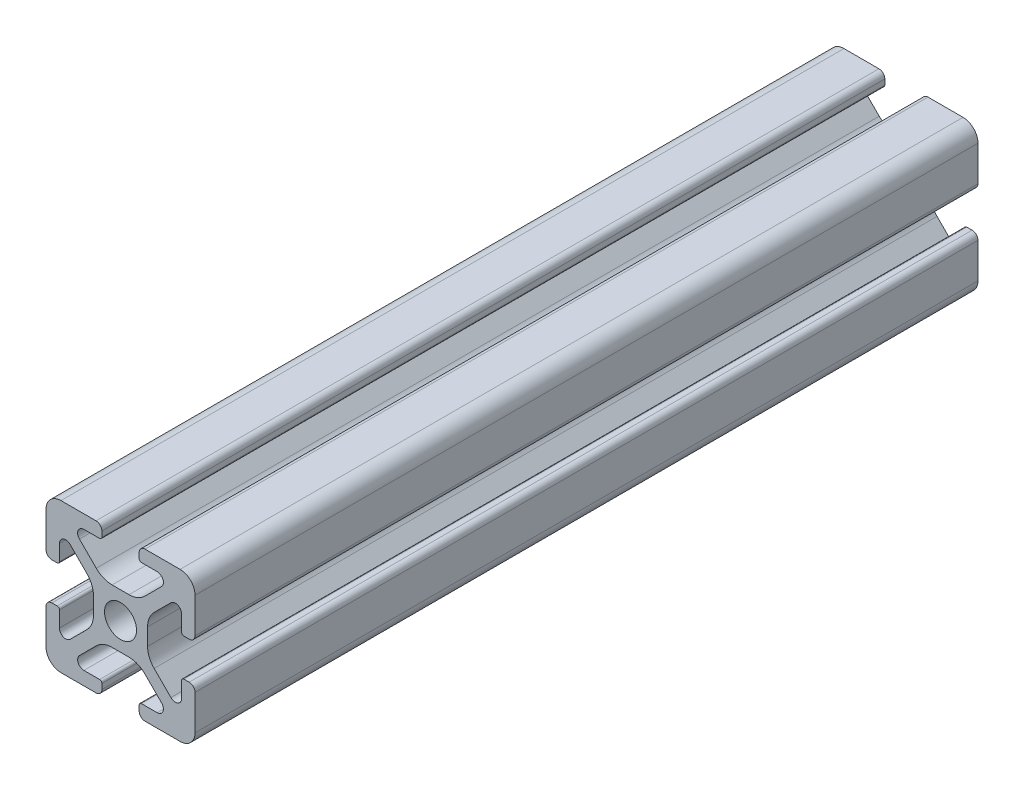
from build123d import *

# Parameters (mm, degrees)
SKETCH1_R           = 2.1463
BOSS_EXTRUDE1_DEPTH = 52.5


with BuildPart() as part:
    # Sketch1 → Boss-Extrude1 (new body, symmetric)
    with BuildSketch(Plane.XY):
        with BuildLine():
            Line((-9.9949, 7.9883), (-9.9949, 3.2893))
            ThreePointArc((-9.9949, 3.2893), (-9.76427588, 2.73252412), (-9.2075, 2.5019))
            Line((-9.2075, 2.5019), (-8.4963, 2.5019))
            ThreePointArc((-8.4963, 2.5019), (-8.280773853, 2.591173853), (-8.1915, 2.8067))
            Line((-8.1915, 2.8067), (-8.1915, 4.9149))
            ThreePointArc((-8.1915, 4.9149), (-7.674065253, 5.689295824), (-6.760603096, 5.507596904))
            Line((-6.760603096, 5.507596904), (-4.505765747, 3.252759555))
            ThreePointArc((-4.505765747, 3.252759555), (-3.856054457, 2.280397894), (-3.627906192, 1.133419111))
            Line((-3.627906192, 1.133419111), (-3.627906192, -1.133419111))
            ThreePointArc((-3.627906192, -1.133419111), (-3.856054457, -2.280397894), (-4.505765747, -3.252759555))
            Line((-4.505765747, -3.252759555), (-6.760603096, -5.507596904))
            ThreePointArc((-6.760603096, -5.507596904), (-7.674065253, -5.689295824), (-8.1915, -4.9149))
            Line((-8.1915, -4.9149), (-8.1915, -2.8067))
            ThreePointArc((-8.1915, -2.8067), (-8.280773853, -2.591173853), (-8.4963, -2.5019))
            Line((-8.4963, -2.5019), (-9.2075, -2.5019))
            ThreePointArc((-9.2075, -2.5019), (-9.76427588, -2.73252412), (-9.9949, -3.2893))
            Line((-9.9949, -3.2893), (-9.9949, -7.9883))
            ThreePointArc((-9.9949, -7.9883), (-9.407180467, -9.407180467), (-7.9883, -9.9949))
            Line((-7.9883, -9.9949), (-3.2893, -9.9949))
            ThreePointArc((-3.2893, -9.9949), (-2.73252412, -9.76427588), (-2.5019, -9.2075))
            Line((-2.5019, -9.2075), (-2.5019, -8.4963))
            ThreePointArc((-2.5019, -8.4963), (-2.591173853, -8.280773853), (-2.8067, -8.1915))
            Line((-2.8067, -8.1915), (-4.9149, -8.1915))
            ThreePointArc((-4.9149, -8.1915), (-5.689295824, -7.674065253), (-5.507596904, -6.760603096))
            Line((-5.507596904, -6.760603096), (-3.252759555, -4.505765747))
            ThreePointArc((-3.252759555, -4.505765747), (-2.280397894, -3.856054457), (-1.133419111, -3.627906192))
            Line((-1.133419111, -3.627906192), (1.133419111, -3.627906192))
            ThreePointArc((1.133419111, -3.627906192), (2.280397894, -3.856054457), (3.252759555, -4.505765747))
            Line((3.252759555, -4.505765747), (5.507596904, -6.760603096))
            ThreePointArc((5.507596904, -6.760603096), (5.689295824, -7.674065253), (4.9149, -8.1915))
            Line((4.9149, -8.1915), (2.8067, -8.1915))
            ThreePointArc((2.8067, -8.1915), (2.591173853, -8.280773853), (2.5019, -8.4963))
            Line((2.5019, -8.4963), (2.5019, -9.2075))
            ThreePointArc((2.5019, -9.2075), (2.73252412, -9.76427588), (3.2893, -9.9949))
            Line((3.2893, -9.9949), (7.9883, -9.9949))
            ThreePointArc((7.9883, -9.9949), (9.407180467, -9.407180467), (9.9949, -7.9883))
            Line((9.9949, -7.9883), (9.9949, -3.2893))
            ThreePointArc((9.9949, -3.2893), (9.76427588, -2.73252412), (9.2075, -2.5019))
            Line((9.2075, -2.5019), (8.4963, -2.5019))
            ThreePointArc((8.4963, -2.5019), (8.280773853, -2.591173853), (8.1915, -2.8067))
            Line((8.1915, -2.8067), (8.1915, -4.9149))
            ThreePointArc((8.1915, -4.9149), (7.674065253, -5.689295824), (6.760603096, -5.507596904))
            Line((6.760603096, -5.507596904), (4.505765747, -3.252759555))
            ThreePointArc((4.505765747, -3.252759555), (3.856054457, -2.280397894), (3.627906192, -1.133419111))
            Line((3.627906192, -1.133419111), (3.627906192, 1.133419111))
            ThreePointArc((3.627906192, 1.133419111), (3.856054457, 2.280397894), (4.505765747, 3.252759555))
            Line((4.505765747, 3.252759555), (6.760603096, 5.507596904))
            ThreePointArc((6.760603096, 5.507596904), (7.674065253, 5.689295824), (8.1915, 4.9149))
            Line((8.1915, 4.9149), (8.1915, 2.8067))
            ThreePointArc((8.1915, 2.8067), (8.280773853, 2.591173853), (8.4963, 2.5019))
            Line((8.4963, 2.5019), (9.2075, 2.5019))
            ThreePointArc((9.2075, 2.5019), (9.76427588, 2.73252412), (9.9949, 3.2893))
            Line((9.9949, 3.2893), (9.9949, 7.9883))
            ThreePointArc((9.9949, 7.9883), (9.407180467, 9.407180467), (7.9883, 9.9949))
            Line((7.9883, 9.9949), (3.2893, 9.9949))
            ThreePointArc((3.2893, 9.9949), (2.73252412, 9.76427588), (2.5019, 9.2075))
            Line((2.5019, 9.2075), (2.5019, 8.4963))
            ThreePointArc((2.5019, 8.4963), (2.591173853, 8.280773853), (2.8067, 8.1915))
            Line((2.8067, 8.1915), (4.9149, 8.1915))
            ThreePointArc((4.9149, 8.1915), (5.689295824, 7.674065253), (5.507596904, 6.760603096))
            Line((5.507596904, 6.760603096), (3.252759555, 4.505765747))
            ThreePointArc((3.252759555, 4.505765747), (2.280397894, 3.856054457), (1.133419111, 3.627906192))
            Line((1.133419111, 3.627906192), (-1.133419111, 3.627906192))
            ThreePointArc((-1.133419111, 3.627906192), (-2.280397894, 3.856054457), (-3.252759555, 4.505765747))
            Line((-3.252759555, 4.505765747), (-5.507596904, 6.760603096))
            ThreePointArc((-5.507596904, 6.760603096), (-5.689295824, 7.674065253), (-4.9149, 8.1915))
            Line((-4.9149, 8.1915), (-2.8067, 8.1915))
            ThreePointArc((-2.8067, 8.1915), (-2.591173853, 8.280773853), (-2.5019, 8.4963))
            Line((-2.5019, 8.4963), (-2.5019, 9.2075))
            ThreePointArc((-2.5019, 9.2075), (-2.73252412, 9.76427588), (-3.2893, 9.9949))
            Line((-3.2893, 9.9949), (-7.9883, 9.9949))
            ThreePointArc((-7.9883, 9.9949), (-9.407180467, 9.407180467), (-9.9949, 7.9883))
        make_face()
        Circle(SKETCH1_R, mode=Mode.SUBTRACT)
    extrude(amount=BOSS_EXTRUDE1_DEPTH, both=True)


solid = part.part
